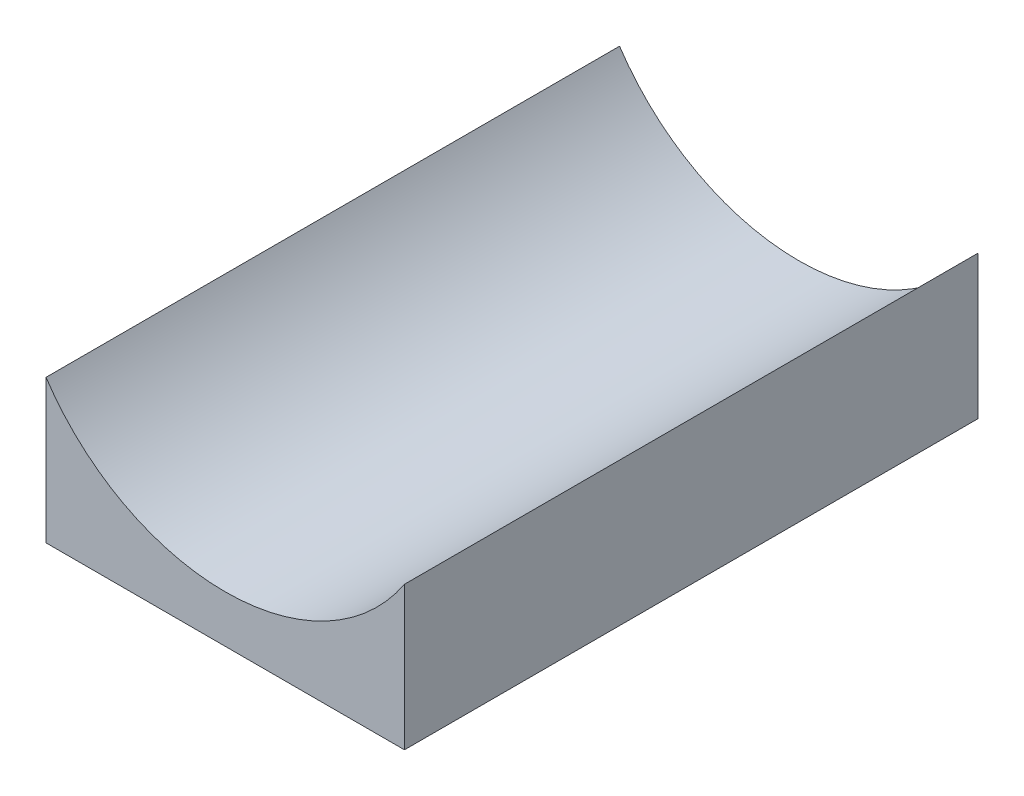
from build123d import *

# Parameters (mm, degrees)
BOSS_EXTRUDE1_DEPTH = 40


with BuildPart() as part:
    # Sketch1 → Boss-Extrude1 (new body)
    with BuildSketch(Plane.XY):
        with BuildLine():
            Line((-12.5, 5), (-12.5, -5))
            Line((-12.5, -5), (12.5, -5))
            Line((12.5, -5), (12.5, 5))
            ThreePointArc((12.5, 5), (0, -1.708438024), (-12.5, 5))
        make_face()
    extrude(amount=BOSS_EXTRUDE1_DEPTH)


solid = part.part
